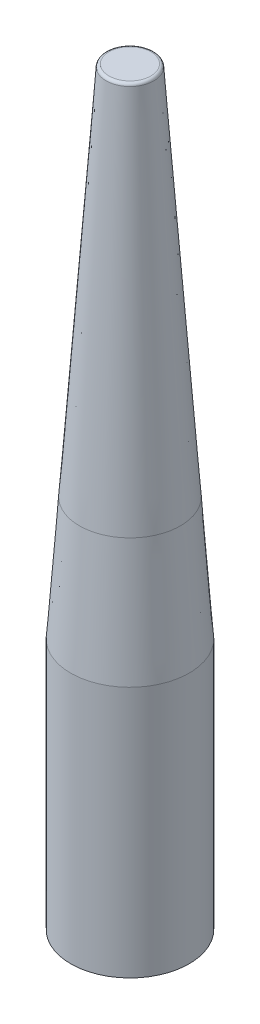
from build123d import *

# Parameters (mm, degrees)
FILLET1_R           = 1.27
SKETCH4_R           = 10.16
BOSS_EXTRUDE1_DEPTH = 12.7
SKETCH5_R           = 10.2235
CUT_EXTRUDE1_DEPTH  = 13.97
CHAMFER1_SIZE       = 1.27


with BuildPart() as part:
    # Sketch1 → Revolve1 (revolve)
    with BuildSketch(Plane.XY):
        Polygon((0, 0), (25.4, 0), (25.4, 107.891110733), (10.155793624, 321.31), (0, 321.31), align=None)
    revolve(axis=Axis((0, 321.31, 0), (0, -1, 0)))

    # Fillet1
    fillet1_edges = [part.edges().sort_by_distance(p)[0] for p in [
        (-10.155793624, 321.31, 0),
    ]]
    fillet(fillet1_edges, radius=FILLET1_R)


with BuildPart() as body_2:
    # Split1: the piece on the far side of the plane
    add(part.part)
    split(bisect_by=Plane(origin=(0, 160.655, 0), x_dir=(1, 0, 0), z_dir=(0, 1, 0)), keep=Keep.BOTTOM)

    # Sketch4 → Boss-Extrude1 (add)
    with BuildSketch(Plane(origin=(0, 160.655, 0), x_dir=(1, 0, 0), z_dir=(0, 1, 0))):
        Circle(SKETCH4_R)
    extrude(amount=BOSS_EXTRUDE1_DEPTH)


with BuildPart() as part_1:
    add(part.part)

    # Split1
    split(bisect_by=Plane(origin=(0, 160.655, 0), x_dir=(1, 0, 0), z_dir=(0, 1, 0)), keep=Keep.TOP)

    # Sketch5 → Cut-Extrude1 (cut)
    with BuildSketch(Plane.XZ.offset(-160.655)):
        Circle(SKETCH5_R)
    extrude(amount=-CUT_EXTRUDE1_DEPTH, mode=Mode.SUBTRACT)

    # Chamfer1
    chamfer1_edges = [part_1.edges().sort_by_distance(p)[0] for p in [
        (-10.2235, 160.655, 0),
    ]]
    chamfer(chamfer1_edges, length=CHAMFER1_SIZE)


solid = Compound([body_2.part, part_1.part])
